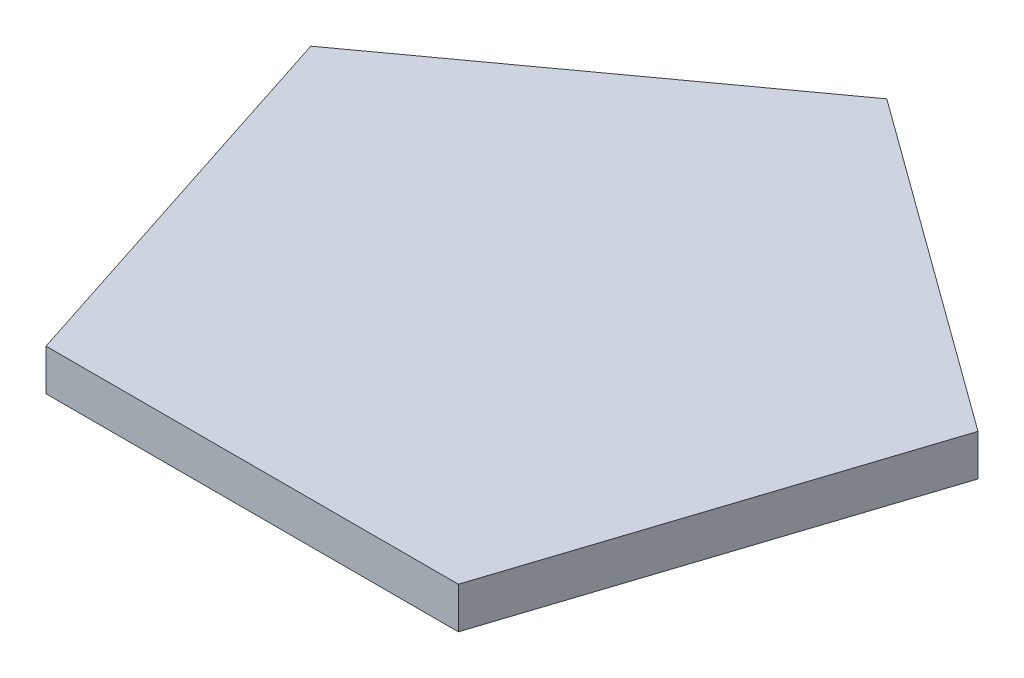
from build123d import *

# Parameters (mm, degrees)
BOSS_EXTRUDE1_DEPTH = 2.54


with BuildPart() as part:
    # Sketch1 → Boss-Extrude1 (new body)
    with BuildSketch(Plane(origin=(0, 0, 0), x_dir=(1, 0, 0), z_dir=(0, 1, 0))):
        Polygon((0, 21.606530532), (-20.549031657, 6.676785124), (-12.7, -17.48005039), (12.7, -17.48005039), (20.549031657, 6.676785124), align=None)
    extrude(amount=BOSS_EXTRUDE1_DEPTH)


solid = part.part
